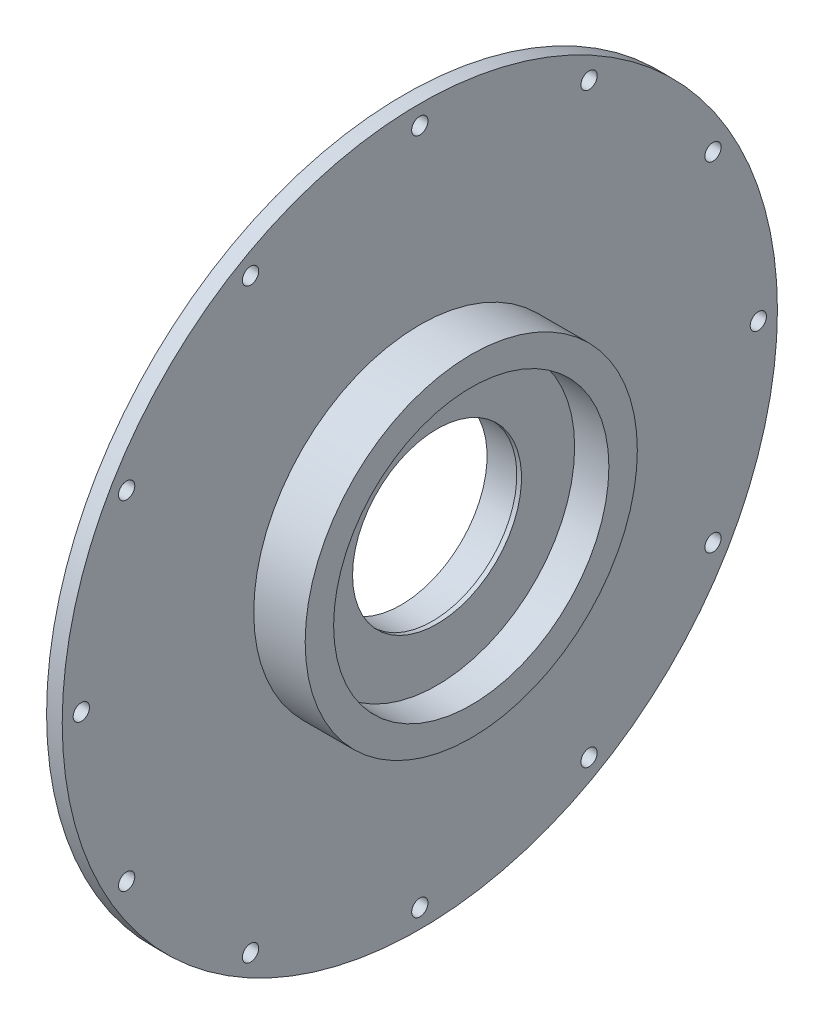
from build123d import *

# Parameters (mm, degrees)
SKETCH2_R          = 2.6
CUT_EXTRUDE1_DEPTH = 10


with BuildPart() as part:
    # Sketch1 → Revolve1 (revolve)
    with BuildSketch(Plane.XY):
        Polygon((0, 27.5), (10, 27.5), (10, 27), (11.5, 27), (11.5, 43.989032899), (22.436374316, 43.989032899), (22.436374316, 53.08402355), (6, 53.08402355), (6, 114.3), (1, 114.3), (1, 104), (2.5, 104), (2.5, 102.5), (0.5, 102.5), (-0.5, 102.2), (-0.5, 100.5), (2.5, 100.5), (5, 98.23), (5, 73.23), (0, 35.229488808), align=None)
    revolve(axis=Axis((0, 0, 0), (1, 0, 0)))

    # Sketch2 → Cut-Extrude1 (cut)
    with BuildSketch(Plane(origin=(0, 0, 0), x_dir=(0, 0, -1), z_dir=(1, 0, 0))):
        with Locations((0, 108.2)):
            Circle(SKETCH2_R)
        with Locations((54.1, 93.703948689)):
            Circle(SKETCH2_R)
        with Locations((93.703948689, 54.1)):
            Circle(SKETCH2_R)
        with Locations((108.2, 0)):
            Circle(SKETCH2_R)
        with Locations((93.703948689, -54.1)):
            Circle(SKETCH2_R)
        with Locations((54.1, -93.703948689)):
            Circle(SKETCH2_R)
        with Locations((0, -108.2)):
            Circle(SKETCH2_R)
        with Locations((-54.1, -93.703948689)):
            Circle(SKETCH2_R)
        with Locations((-93.703948689, -54.1)):
            Circle(SKETCH2_R)
        with Locations((-108.2, 0)):
            Circle(SKETCH2_R)
        with Locations((-93.703948689, 54.1)):
            Circle(SKETCH2_R)
        with Locations((-54.1, 93.703948689)):
            Circle(SKETCH2_R)
    extrude(amount=CUT_EXTRUDE1_DEPTH, mode=Mode.SUBTRACT)


solid = part.part
